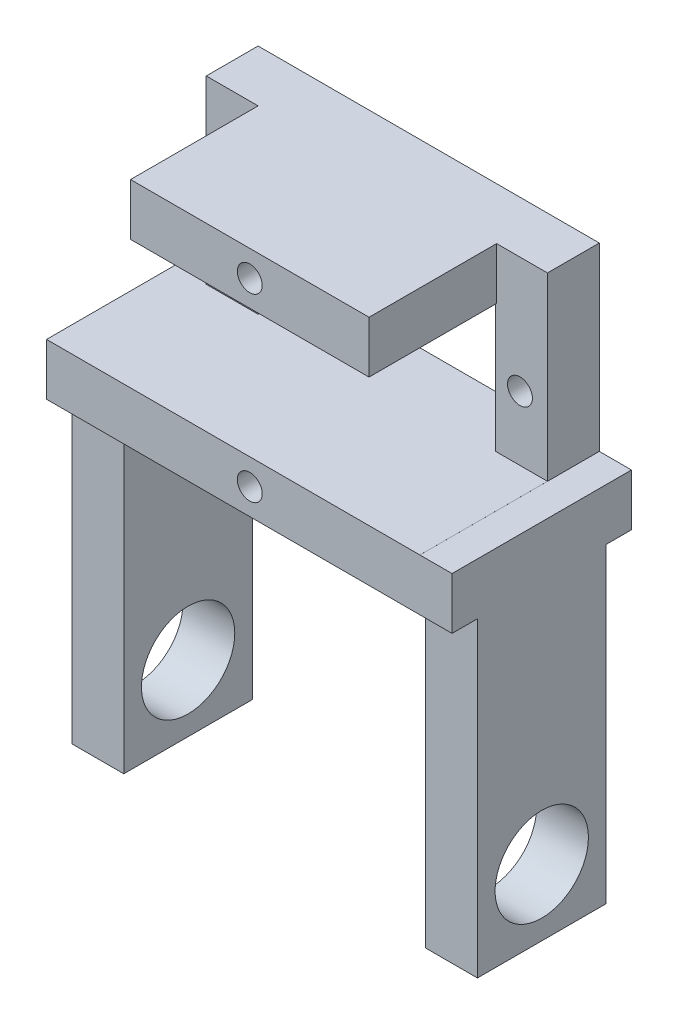
from build123d import *

# Parameters (mm, degrees)
SKETCH1_W           = 32.9
SKETCH1_H           = 22.4
BOSS_EXTRUDE1_DEPTH = 5
SKETCH2_R           = 1.2
SKETCH2_W           = 22.9
SKETCH2_H           = 12.4
CUT_EXTRUDE2_DEPTH  = 5
SKETCH3_W           = 22.996888994
SKETCH3_H           = 5
BOSS_EXTRUDE2_DEPTH = 12.3
SKETCH4_R           = 1.2
CUT_EXTRUDE3_DEPTH  = 5
SKETCH6_W           = 5
SKETCH6_H           = 5
SKETCH6_W_2         = 4.903111006
BOSS_EXTRUDE3_DEPTH = 12.3
SKETCH8_W           = 17.3
SKETCH8_H           = 4.998204887
BOSS_EXTRUDE4_DEPTH = 3.1
SKETCH9_W           = 17.3
SKETCH9_H           = 5
BOSS_EXTRUDE5_DEPTH = 3.1
SKETCH18_W          = 5
SKETCH18_H          = 12.4
BOSS_EXTRUDE7_DEPTH = 30
SKETCH19_R          = 4.5
CUT_EXTRUDE6_DEPTH  = 30
SKETCH20_R          = 4.5
CUT_EXTRUDE7_DEPTH  = 30
SKETCH10_W          = 5
SKETCH10_H          = 12.4
BOSS_EXTRUDE6_DEPTH = 30
SKETCH21_R          = 4.5
CUT_EXTRUDE8_DEPTH  = 10
SKETCH22_R          = 4.5
CUT_EXTRUDE9_DEPTH  = 10
CUT_EXTRUDE10_DEPTH = 3


with BuildPart() as part:
    # Sketch1 → Boss-Extrude1 (new body)
    with BuildSketch(Plane.XY):
        Rectangle(SKETCH1_W, SKETCH1_H)
    extrude(amount=BOSS_EXTRUDE1_DEPTH)

    # Sketch2 → Cut-Extrude2 (cut)
    with BuildSketch(Plane.XY.offset(5)):
        with Locations((13.8, 0)):
            Circle(SKETCH2_R)
        with Locations((-13.8, 0)):
            Circle(SKETCH2_R)
        Rectangle(SKETCH2_W, SKETCH2_H)
    extrude(amount=-CUT_EXTRUDE2_DEPTH, mode=Mode.SUBTRACT)

    # Sketch3 → Boss-Extrude2 (add)
    with BuildSketch(Plane.XY.offset(5)):
        with Locations((0.048444497, 8.7)):
            Rectangle(SKETCH3_W, SKETCH3_H)
        with Locations((0.048444497, -8.7)):
            Rectangle(SKETCH3_W, SKETCH3_H)
    extrude(amount=BOSS_EXTRUDE2_DEPTH)

    # Sketch4 → Cut-Extrude3 (cut)
    with BuildSketch(Plane.XY.offset(17.3)):
        with Locations((0.048444497, 8.7)):
            Circle(SKETCH4_R)
        with Locations((0.048444497, -8.7)):
            Circle(SKETCH4_R)
    extrude(amount=-CUT_EXTRUDE3_DEPTH, mode=Mode.SUBTRACT)

    # Sketch6 → Boss-Extrude3 (add)
    with BuildSketch(Plane.XY.offset(5)):
        with Locations((-13.95, -8.7)):
            Rectangle(SKETCH6_W, SKETCH6_H)
        with Locations((13.998444497, -8.7)):
            Rectangle(SKETCH6_W_2, SKETCH6_H)
    extrude(amount=BOSS_EXTRUDE3_DEPTH)

    # Sketch8 → Boss-Extrude4 (add)
    with BuildSketch(Plane(origin=(16.45, 0, 0), x_dir=(0, 0, -1), z_dir=(1, 0, 0))):
        with Locations((-8.65, -8.700897557)):
            Rectangle(SKETCH8_W, SKETCH8_H)
    extrude(amount=BOSS_EXTRUDE4_DEPTH)

    # Sketch9 → Boss-Extrude5 (add)
    with BuildSketch(Plane.ZY.offset(16.45)):
        with Locations((8.65, -8.7)):
            Rectangle(SKETCH9_W, SKETCH9_H)
    extrude(amount=BOSS_EXTRUDE5_DEPTH)

    # Sketch18 → Boss-Extrude7 (add)
    with BuildSketch(Plane.XZ.offset(11.2)):
        with Locations((-17.05, 8.65)):
            Rectangle(SKETCH18_W, SKETCH18_H)
        with Locations((17.05, 8.65)):
            Rectangle(SKETCH18_W, SKETCH18_H)
    extrude(amount=BOSS_EXTRUDE7_DEPTH)

    # Sketch19 → Cut-Extrude6 (cut)
    with BuildSketch(Plane.ZY.offset(19.55)):
        with Locations((8.65, -34.8)):
            Circle(SKETCH19_R)
    extrude(amount=-CUT_EXTRUDE6_DEPTH, mode=Mode.SUBTRACT)

    # Sketch20 → Cut-Extrude7 (cut)
    with BuildSketch(Plane(origin=(19.55, 0, 0), x_dir=(0, 0, -1), z_dir=(1, 0, 0))):
        with Locations((-8.65, -34.8)):
            Circle(SKETCH20_R)
    extrude(amount=-CUT_EXTRUDE7_DEPTH, mode=Mode.SUBTRACT)

    # Sketch10 → Boss-Extrude6 (add)
    with BuildSketch(Plane.XZ.offset(11.2)):
        with Locations((17.05, 8.65)):
            Rectangle(SKETCH10_W, SKETCH10_H)
        with Locations((-17.05, 8.65)):
            Rectangle(SKETCH10_W, SKETCH10_H)
    extrude(amount=BOSS_EXTRUDE6_DEPTH)

    # Sketch21 → Cut-Extrude8 (cut)
    with BuildSketch(Plane(origin=(19.55, 0, 0), x_dir=(0, 0, -1), z_dir=(1, 0, 0))):
        with Locations((-8.65, -34.8)):
            Circle(SKETCH21_R)
    extrude(amount=-CUT_EXTRUDE8_DEPTH, mode=Mode.SUBTRACT)

    # Sketch22 → Cut-Extrude9 (cut)
    with BuildSketch(Plane(origin=(-14.55, 0, 0), x_dir=(0, 0, -1), z_dir=(1, 0, 0))):
        with Locations((-8.65, -34.8)):
            Circle(SKETCH22_R)
    extrude(amount=-CUT_EXTRUDE9_DEPTH, mode=Mode.SUBTRACT)

    # Sketch23 → Cut-Extrude10 (cut)
    with BuildSketch(Plane.ZY.offset(19.55)):
        with BuildLine():
            Line((5.65, -22.3), (4.674239456, -32.692079676))
            ThreePointArc((4.674239456, -32.692079676), (8.65, -30.3), (12.625760544, -32.692079676))
            Line((12.625760544, -32.692079676), (11.65, -22.3))
            ThreePointArc((11.65, -22.3), (8.65, -19.3), (5.65, -22.3))
        make_face()
    extrude(amount=-CUT_EXTRUDE10_DEPTH, mode=Mode.SUBTRACT)


solid = part.part
